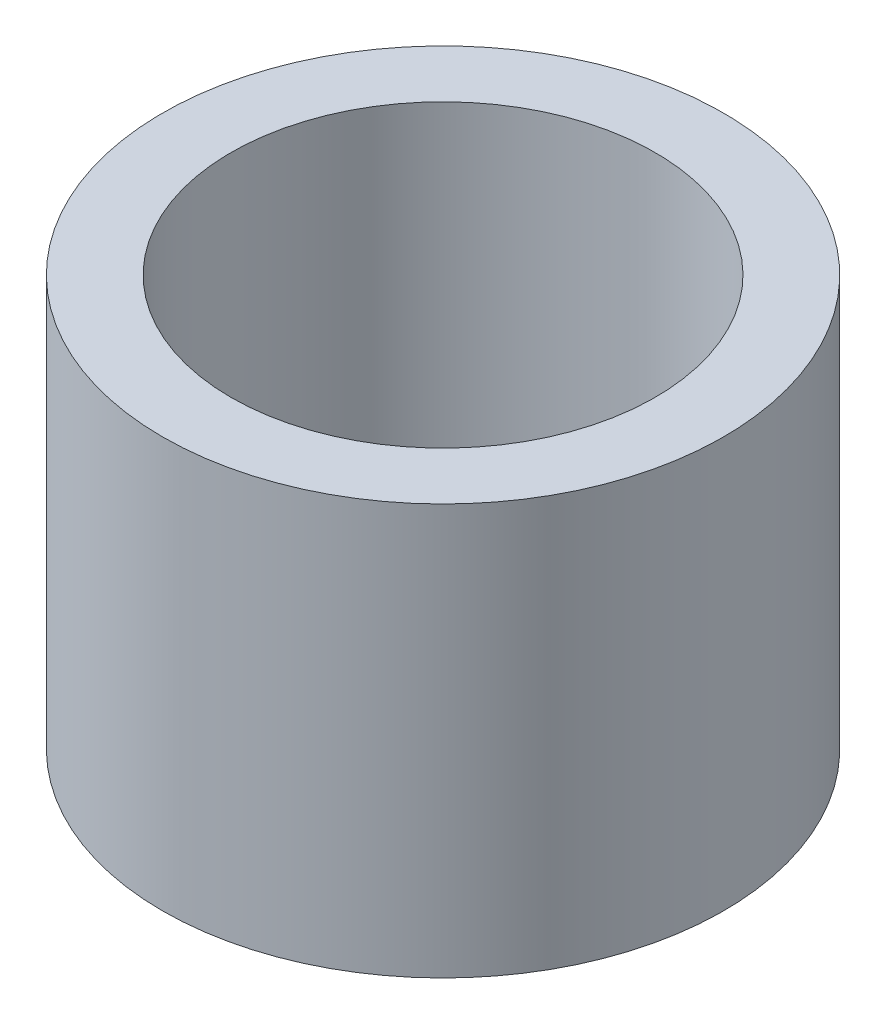
from build123d import *

# Parameters (mm, degrees)
SKETCH1_R           = 4.1
SKETCH1_R_2         = 3.1
BOSS_EXTRUDE1_DEPTH = 6


with BuildPart() as part:
    # Sketch1 → Boss-Extrude1 (new body)
    with BuildSketch(Plane(origin=(0, 0, 0), x_dir=(1, 0, 0), z_dir=(0, 1, 0))):
        Circle(SKETCH1_R)
        Circle(SKETCH1_R_2, mode=Mode.SUBTRACT)
    extrude(amount=BOSS_EXTRUDE1_DEPTH)


solid = part.part
